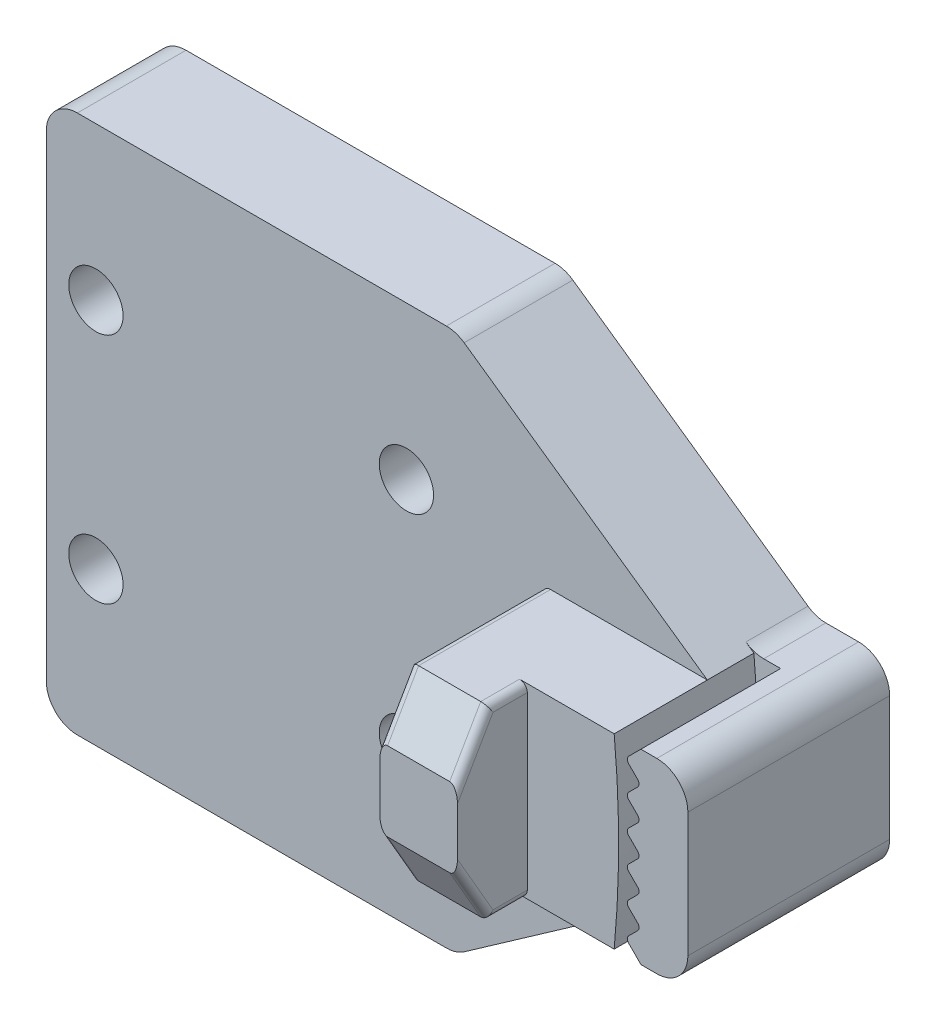
from build123d import *
from OCP.BRepFilletAPI import BRepFilletAPI_MakeChamfer

# Parameters (mm, degrees)
EXTRUDE_1_DEPTH        = 4
EXTRUDE_1_DEPTH_BACK   = 3
SKETCH_1_R             = 1.75
EXTRUDE_1_2_DEPTH      = 4
EXTRUDE_1_2_DEPTH_BACK = 3
EXTRUDE_START          = 4
EXTRUDE_2_DEPTH        = 6
EXTRUDE_3_DEPTH        = 1
EXTRUDE_3_DEPTH_BACK   = 3
FILLET_1_R             = 2
SKETCH_2_W             = 5
SKETCH_2_H             = 12.015250562
EXTRUDE_4_DEPTH        = 10.5
CHAMFER_2_SIZE         = 2
CHAMFER_2_SIZE2        = 3.464101615
FILLET_2_R             = 0.5


with BuildPart() as part:
    # Эскиз1 → Бобышка-Вытянуть1 (new, two sides: drawn at the far end of the back side and taken through both)
    with BuildSketch(Plane.XY.offset(-EXTRUDE_1_DEPTH_BACK)):
        with BuildLine():
            Line((-13.335192836, 17.461834668), (-13.335192836, -17.238165332))
            Line((-13.335192836, -17.238165332), (13.064807164, -17.238165332))
            Line((13.064807164, -17.238165332), (29.24315013, -5.895849196))
            ThreePointArc((29.24315013, -5.895849196), (29.53124223, 0.111776085), (29.24315013, 6.119401366))
            Line((29.24315013, 6.119401366), (13.064807164, 17.461834668))
            Line((13.064807164, 17.461834668), (-13.335192836, 17.461834668))
        make_face()
        with Locations((-10.14124139, -7.388165332)):
            Circle(SKETCH_1_R, mode=Mode.SUBTRACT)
        with Locations((9.85875861, -7.388165332)):
            Circle(SKETCH_1_R, mode=Mode.SUBTRACT)
        with Locations((-10.14124139, 7.611834668)):
            Circle(SKETCH_1_R, mode=Mode.SUBTRACT)
        with Locations((9.85875861, 7.611834668)):
            Circle(SKETCH_1_R, mode=Mode.SUBTRACT)
    extrude(amount=EXTRUDE_1_DEPTH + EXTRUDE_1_DEPTH_BACK)



with BuildPart() as body_2:
    # Эскиз1 → Extrude 1 2 (new, two sides: drawn at the far end of the back side and taken through both)
    with BuildSketch(Plane.XY.offset(-EXTRUDE_1_2_DEPTH_BACK)):
        with BuildLine():
            Line((30.969143909, -5.894657137), (30.967951851, -5.895849196))
            Line((30.967951851, -5.895849196), (33.989360696, -5.895849196))
            Line((33.989360696, -5.895849196), (33.989360696, 6.119401366))
            Line((33.989360696, 6.119401366), (30.963902746, 6.119401366))
            Line((30.963902746, 6.119401366), (30.178059332, 5.333557953))
            ThreePointArc((30.178059332, 5.333557953), (30.090191367, 5.121425918), (30.178059332, 4.909293884))
            Line((30.178059332, 4.909293884), (30.757011875, 4.330341341))
            ThreePointArc((30.757011875, 4.330341341), (30.84487984, 4.118209307), (30.757011875, 3.906077273))
            Line((30.757011875, 3.906077273), (30.181275944, 3.330341341))
            ThreePointArc((30.181275944, 3.330341341), (30.093407978, 3.118209307), (30.181275944, 2.906077273))
            Line((30.181275944, 2.906077273), (30.757011875, 2.330341341))
            ThreePointArc((30.757011875, 2.330341341), (30.84487984, 2.118209307), (30.757011875, 1.906077273))
            Line((30.757011875, 1.906077273), (30.178059332, 1.32712473))
            ThreePointArc((30.178059332, 1.32712473), (30.090191367, 1.114992696), (30.178059332, 0.902860662))
            Line((30.178059332, 0.902860662), (30.757011875, 0.323908119))
            ThreePointArc((30.757011875, 0.323908119), (30.84487984, 0.111776085), (30.757011875, -0.10035595))
            Line((30.757011875, -0.10035595), (30.181275944, -0.676091881))
            ThreePointArc((30.181275944, -0.676091881), (30.093407978, -0.888223915), (30.181275944, -1.10035595))
            Line((30.181275944, -1.10035595), (30.757011875, -1.676091881))
            ThreePointArc((30.757011875, -1.676091881), (30.84487984, -1.888223915), (30.757011875, -2.10035595))
            Line((30.757011875, -2.10035595), (30.178059332, -2.679308492))
            ThreePointArc((30.178059332, -2.679308492), (30.090191367, -2.891440526), (30.178059332, -3.103572561))
            Line((30.178059332, -3.103572561), (30.757011875, -3.682525103))
            ThreePointArc((30.757011875, -3.682525103), (30.84487984, -3.894657137), (30.757011875, -4.106789172))
            Line((30.757011875, -4.106789172), (30.181275944, -4.682525103))
            ThreePointArc((30.181275944, -4.682525103), (30.093407978, -4.894657137), (30.181275944, -5.106789172))
            Line((30.181275944, -5.106789172), (30.969143909, -5.894657137))
        make_face()
    extrude(amount=EXTRUDE_1_2_DEPTH + EXTRUDE_1_2_DEPTH_BACK)


with BuildPart() as part_1:
    add(part.part)

    add(body_2.part)  # Бобышка-Вытянуть2 merges body 2
    # Эскиз1<3> → Бобышка-Вытянуть2 (add)
    with BuildSketch(Plane.XY.offset(EXTRUDE_START)):
        with BuildLine():
            Line((21.86916953, -5.895849196), (29.24315013, -5.895849196))
            ThreePointArc((29.24315013, -5.895849196), (29.53124223, 0.111776085), (29.24315013, 6.119401366))
            Line((29.24315013, 6.119401366), (21.86916953, 6.119401366))
            Line((21.86916953, 6.119401366), (21.86916953, -5.895849196))
        make_face()
        with BuildLine():
            Line((30.969143909, -5.894657137), (30.967951851, -5.895849196))
            Line((30.967951851, -5.895849196), (33.989360696, -5.895849196))
            Line((33.989360696, -5.895849196), (33.989360696, 6.119401366))
            Line((33.989360696, 6.119401366), (30.963902746, 6.119401366))
            Line((30.963902746, 6.119401366), (30.178059332, 5.333557953))
            ThreePointArc((30.178059332, 5.333557953), (30.090191367, 5.121425918), (30.178059332, 4.909293884))
            Line((30.178059332, 4.909293884), (30.757011875, 4.330341341))
            ThreePointArc((30.757011875, 4.330341341), (30.84487984, 4.118209307), (30.757011875, 3.906077273))
            Line((30.757011875, 3.906077273), (30.181275944, 3.330341341))
            ThreePointArc((30.181275944, 3.330341341), (30.093407978, 3.118209307), (30.181275944, 2.906077273))
            Line((30.181275944, 2.906077273), (30.757011875, 2.330341341))
            ThreePointArc((30.757011875, 2.330341341), (30.84487984, 2.118209307), (30.757011875, 1.906077273))
            Line((30.757011875, 1.906077273), (30.178059332, 1.32712473))
            ThreePointArc((30.178059332, 1.32712473), (30.090191367, 1.114992696), (30.178059332, 0.902860662))
            Line((30.178059332, 0.902860662), (30.757011875, 0.323908119))
            ThreePointArc((30.757011875, 0.323908119), (30.84487984, 0.111776085), (30.757011875, -0.10035595))
            Line((30.757011875, -0.10035595), (30.181275944, -0.676091881))
            ThreePointArc((30.181275944, -0.676091881), (30.093407978, -0.888223915), (30.181275944, -1.10035595))
            Line((30.181275944, -1.10035595), (30.757011875, -1.676091881))
            ThreePointArc((30.757011875, -1.676091881), (30.84487984, -1.888223915), (30.757011875, -2.10035595))
            Line((30.757011875, -2.10035595), (30.178059332, -2.679308492))
            ThreePointArc((30.178059332, -2.679308492), (30.090191367, -2.891440526), (30.178059332, -3.103572561))
            Line((30.178059332, -3.103572561), (30.757011875, -3.682525103))
            ThreePointArc((30.757011875, -3.682525103), (30.84487984, -3.894657137), (30.757011875, -4.106789172))
            Line((30.757011875, -4.106789172), (30.181275944, -4.682525103))
            ThreePointArc((30.181275944, -4.682525103), (30.093407978, -4.894657137), (30.181275944, -5.106789172))
            Line((30.181275944, -5.106789172), (30.969143909, -5.894657137))
        make_face()
    extrude(amount=EXTRUDE_2_DEPTH)

    # Эскиз1<4> → Бобышка-Вытянуть3 (add, two sides: drawn at the far end of the back side and taken through both)
    with BuildSketch(Plane.XY.offset(-EXTRUDE_3_DEPTH_BACK)):
        with BuildLine():
            ThreePointArc((29.24315013, 6.119401366), (29.53124223, 0.111776085), (29.24315013, -5.895849196))
            Line((29.24315013, -5.895849196), (30.967951851, -5.895849196))
            Line((30.967951851, -5.895849196), (30.969143909, -5.894657137))
            Line((30.969143909, -5.894657137), (30.181275944, -5.106789172))
            ThreePointArc((30.181275944, -5.106789172), (30.093407978, -4.894657137), (30.181275944, -4.682525103))
            Line((30.181275944, -4.682525103), (30.757011875, -4.106789172))
            ThreePointArc((30.757011875, -4.106789172), (30.84487984, -3.894657137), (30.757011875, -3.682525103))
            Line((30.757011875, -3.682525103), (30.178059332, -3.103572561))
            ThreePointArc((30.178059332, -3.103572561), (30.090191367, -2.891440526), (30.178059332, -2.679308492))
            Line((30.178059332, -2.679308492), (30.757011875, -2.10035595))
            ThreePointArc((30.757011875, -2.10035595), (30.84487984, -1.888223915), (30.757011875, -1.676091881))
            Line((30.757011875, -1.676091881), (30.181275944, -1.10035595))
            ThreePointArc((30.181275944, -1.10035595), (30.093407978, -0.888223915), (30.181275944, -0.676091881))
            Line((30.181275944, -0.676091881), (30.757011875, -0.10035595))
            ThreePointArc((30.757011875, -0.10035595), (30.84487984, 0.111776085), (30.757011875, 0.323908119))
            Line((30.757011875, 0.323908119), (30.178059332, 0.902860662))
            ThreePointArc((30.178059332, 0.902860662), (30.090191367, 1.114992696), (30.178059332, 1.32712473))
            Line((30.178059332, 1.32712473), (30.757011875, 1.906077273))
            ThreePointArc((30.757011875, 1.906077273), (30.84487984, 2.118209307), (30.757011875, 2.330341341))
            Line((30.757011875, 2.330341341), (30.181275944, 2.906077273))
            ThreePointArc((30.181275944, 2.906077273), (30.093407978, 3.118209307), (30.181275944, 3.330341341))
            Line((30.181275944, 3.330341341), (30.757011875, 3.906077273))
            ThreePointArc((30.757011875, 3.906077273), (30.84487984, 4.118209307), (30.757011875, 4.330341341))
            Line((30.757011875, 4.330341341), (30.178059332, 4.909293884))
            ThreePointArc((30.178059332, 4.909293884), (30.090191367, 5.121425918), (30.178059332, 5.333557953))
            Line((30.178059332, 5.333557953), (30.963902746, 6.119401366))
            Line((30.963902746, 6.119401366), (29.24315013, 6.119401366))
        make_face()
    extrude(amount=EXTRUDE_3_DEPTH + EXTRUDE_3_DEPTH_BACK)

    # Скругление1
    fillet_1_edges = [part_1.edges().sort_by_distance(p)[0] for p in [
        (13.064807164, 17.461834668, 0.5),
        (13.064807164, -17.238165332, 0.5),
        (-13.335192836, -17.238165332, 0.5),
        (-13.335192836, 17.461834668, 0.5),
        (33.989360696, -5.895849196, 3.5),
        (33.989360696, 6.119401366, 3.5),
        (29.24315013, -5.895849196, -1),
        (29.24315013, 6.119401366, -1),
    ]]
    fillet(fillet_1_edges, radius=FILLET_1_R)

    # Эскиз2 → Бобышка-Вытянуть4 (add)
    with BuildSketch(Plane.XY.offset(4)):
        with Locations((21.146996963, 0.111776085)):
            Rectangle(SKETCH_2_W, SKETCH_2_H)
    extrude(amount=EXTRUDE_4_DEPTH)

    # Фаска2: one chamfer whose edges measure the first distance from different faces: ONE call of the kernel's chamfer builder (chamfer() names one face for all edges)
    chamfer_2_edges_1 = [part_1.edges().sort_by_distance(p)[0] for p in [
        (21.146996963, -5.895849196, 14.5),
    ]]
    chamfer_2_side_1 = [part_1.faces().sort_by_distance(p)[0] for p in [
        (23.213672797, -5.895849196, 8.3723191),
    ]]
    chamfer_2_edges_2 = [part_1.edges().sort_by_distance(p)[0] for p in [
        (21.146996963, 6.119401366, 14.5),
    ]]
    chamfer_2_side_2 = [part_1.faces().sort_by_distance(p)[0] for p in [
        (23.213672797, 6.119401366, 8.3723191),
    ]]
    chamfer_2 = BRepFilletAPI_MakeChamfer(part_1.part.solid().wrapped)
    for e in chamfer_2_edges_1:
        chamfer_2.Add(CHAMFER_2_SIZE, CHAMFER_2_SIZE2, e.wrapped, chamfer_2_side_1[0].wrapped)  # the first distance lies on this face
    for e in chamfer_2_edges_2:
        chamfer_2.Add(CHAMFER_2_SIZE, CHAMFER_2_SIZE2, e.wrapped, chamfer_2_side_2[0].wrapped)  # the first distance lies on this face
    add(Compound.cast(chamfer_2.Shape()), mode=Mode.REPLACE)

    # Скругление2
    fillet_2_edges = [part_1.edges().sort_by_distance(p)[0] for p in [
        (23.646996963, -5.895849196, 11.25),
        (23.646996963, 6.119401366, 11.25),
        (18.646996963, -5.895849196, 8.25),
        (18.646996963, -4.163798388, 13.5),
        (18.646996963, 4.387350558, 13.5),
        (18.646996963, 6.119401366, 8.25),
        (23.646996963, 4.387350558, 13.5),
        (23.646996963, -4.163798388, 13.5),
    ]]
    fillet(fillet_2_edges, radius=FILLET_2_R)


solid = part_1.part
